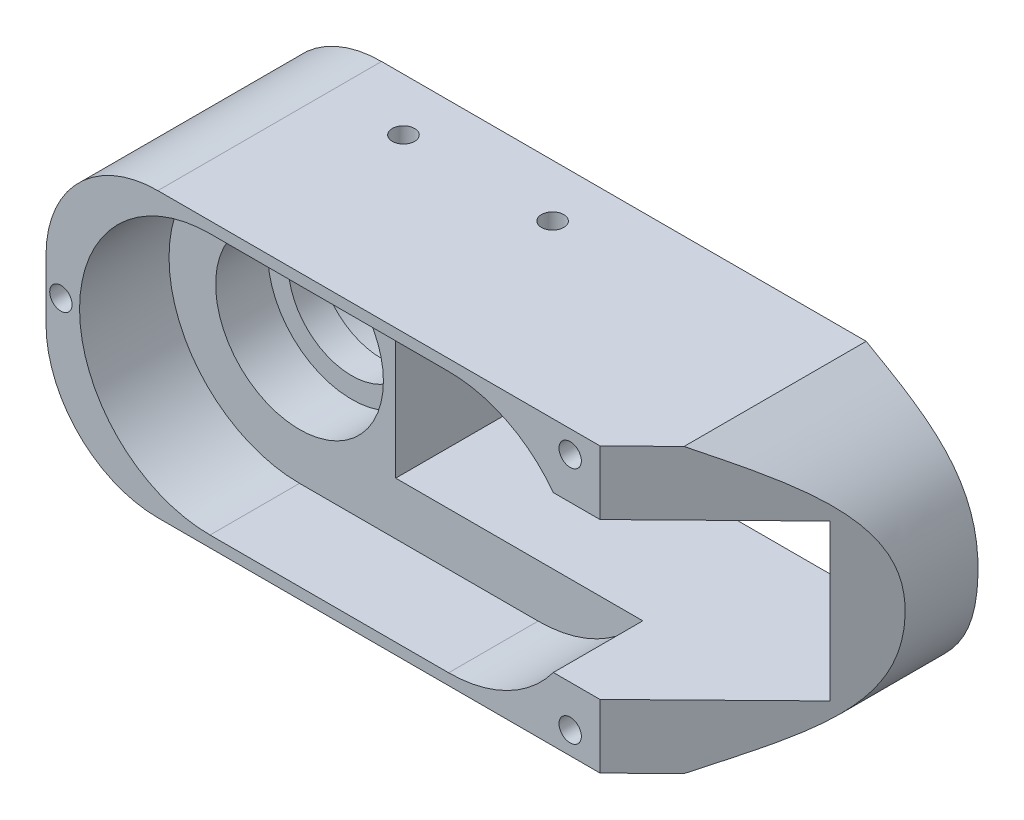
from build123d import *

# Parameters (mm, degrees)
EXTRUDE1_DEPTH                 = 30
EXTRUDE2_DEPTH                 = 12
SKETCH4_R                      = 11.25
EXTRUDE3_DEPTH                 = 7
SKETCH5_R                      = 8.5
EXTRUDE4_DEPTH                 = 12.0000001
SKETCH6_R                      = 11.25
EXTRUDE5_DEPTH                 = 7
SKETCH8_R                      = 2.5
EXTRUDE6_DEPTH                 = 19.0000001
SKETCH7_W                      = 41
SKETCH7_H                      = 20.891455382
EXTRUDE7_DEPTH                 = 31.0000001
SKETCH10_W                     = 55
SKETCH10_H                     = 20.891455382
EXTRUDE8_DEPTH                 = 28
FILLET1_R                      = 15
EXTRUDE17_DEPTH                = 20.0000001
EXTRUDE17_DEPTH_BACK           = 20.0000001
SKETCH19_R                     = 1.5
EXTRUDE19_DEPTH                = 6
F_4_5_4_5_DIAMETER_HOLE1_D     = 4.5
F_4_5_4_5_DIAMETER_HOLE1_DEPTH = 20
F_3_0_3_DIAMETER_HOLE1_D       = 3
F_3_0_3_DIAMETER_HOLE1_DEPTH   = 20


with BuildPart() as part:
    # Sketch1 → Extrude1 (new body)
    with BuildSketch(Plane.XY):
        with BuildLine():
            Line((-50, 19), (30, 19))
            add(Edge.make_bspline(
                [(30, 19), (36.561245044, 15.211863407), (45.16011468, 10.828695002), (44.967612, -11.088320981), (37.933016475, -14.419870803), (30, -19)],
                knots=[0, 0, 0, 0, 0.44562934, 0.54562934, 1, 1, 1, 1], degree=3))
            Line((30, -19), (-50, -19))
            Line((-50, -19), (-50, 19))
        make_face()
    extrude(amount=EXTRUDE1_DEPTH)

    # Sketch2 → Extrude2 (cut)
    with BuildSketch(Plane.XY.offset(30)):
        with BuildLine():
            Line((-28, 17.5), (4, 17.5))
            ThreePointArc((4, 17.5), (21.5, 0), (4, -17.5))
            Line((4, -17.5), (-28, -17.5))
            ThreePointArc((-28, -17.5), (-45.5, 0), (-28, 17.5))
        make_face()
    extrude(amount=-EXTRUDE2_DEPTH, mode=Mode.SUBTRACT)

    # Sketch4 → Extrude3 (cut)
    with BuildSketch(Plane.XY.offset(18)):
        with Locations((-28, 0)):
            Circle(SKETCH4_R)
    extrude(amount=-EXTRUDE3_DEPTH, mode=Mode.SUBTRACT)

    # Sketch5 → Extrude4 (cut, through all)
    with BuildSketch(Plane.XY.offset(11)):
        with Locations((-28, 0)):
            Circle(SKETCH5_R)
    extrude(amount=-EXTRUDE4_DEPTH, mode=Mode.SUBTRACT)

    # Sketch6 → Extrude5 (cut)
    with BuildSketch(Plane(origin=(0, 0, 0), x_dir=(-1, 0, 0), z_dir=(0, 0, -1))):
        with Locations((28, 0)):
            Circle(SKETCH6_R)
    extrude(amount=-EXTRUDE5_DEPTH, mode=Mode.SUBTRACT)

    # Sketch8 → Extrude6 (cut, through all)
    with BuildSketch(Plane.XY.offset(18)):
        with Locations((2, 0)):
            Circle(SKETCH8_R)
    extrude(amount=-EXTRUDE6_DEPTH, mode=Mode.SUBTRACT)

    # Sketch7 → Extrude7 (cut, through all)
    with BuildSketch(Plane(origin=(0, 0, 0), x_dir=(-1, 0, 0), z_dir=(0, 0, -1))):
        with Locations((-12.7, 0)):
            Rectangle(SKETCH7_W, SKETCH7_H)
    extrude(amount=-EXTRUDE7_DEPTH, mode=Mode.SUBTRACT)

    # Sketch10 → Extrude8 (cut)
    with BuildSketch(Plane.XY.offset(30)):
        with Locations((12.4, 0)):
            Rectangle(SKETCH10_W, SKETCH10_H)
    extrude(amount=-EXTRUDE8_DEPTH, mode=Mode.SUBTRACT)

    # Fillet1
    fillet1_edges = [part.edges().sort_by_distance(p)[0] for p in [
        (-50, 19, 15),
        (-50, -19, 15),
    ]]
    fillet(fillet1_edges, radius=FILLET1_R)

    # Sketch17 → Extrude17 (cut, two sides)
    with BuildSketch(Plane(origin=(0, 0, 0), x_dir=(1, 0, 0), z_dir=(0, 1, 0))) as extrude17_sk:
        Polygon((55, 0), (55, -30), (24.297369985, -30), align=None)
    extrude(amount=EXTRUDE17_DEPTH, mode=Mode.SUBTRACT)
    extrude(extrude17_sk.sketch, amount=-EXTRUDE17_DEPTH_BACK, mode=Mode.SUBTRACT)

    # Sketch19 → Extrude19 (cut)
    with BuildSketch(Plane(origin=(0, 19, 0), x_dir=(-1, 0, 0), z_dir=(0, 1, 0))):
        with Locations((5, 7.059888019)):
            Circle(SKETCH19_R)
        with Locations((25, 7.059888019)):
            Circle(SKETCH19_R)
    extrude19 = extrude(amount=-EXTRUDE19_DEPTH, mode=Mode.SUBTRACT)

    # Mirror4: Extrude19 across plane
    add(extrude19.mirror(Plane.ZX), mode=Mode.SUBTRACT)

    # Ø4.5 (4.5) Diameter Hole1
    with Locations(Plane(origin=(36.013200545, 5.004272309, 2), x_dir=(1, 0, 0), z_dir=(0, 0, 1))):
        with Locations((0, 0), (0, -10), (-47.26, 0), (-47.26, -10)):
            Hole(F_4_5_4_5_DIAMETER_HOLE1_D / 2, depth=F_4_5_4_5_DIAMETER_HOLE1_DEPTH)

    # Ø3.0 (3) Diameter Hole1
    with Locations(Plane(origin=(-48, 0, 30), x_dir=(1, 0, 0), z_dir=(0, 0, 1))):
        with Locations((0, 0), (68.297369985, -16), (68.297369985, 16)):
            Hole(F_3_0_3_DIAMETER_HOLE1_D / 2, depth=F_3_0_3_DIAMETER_HOLE1_DEPTH)


solid = part.part
